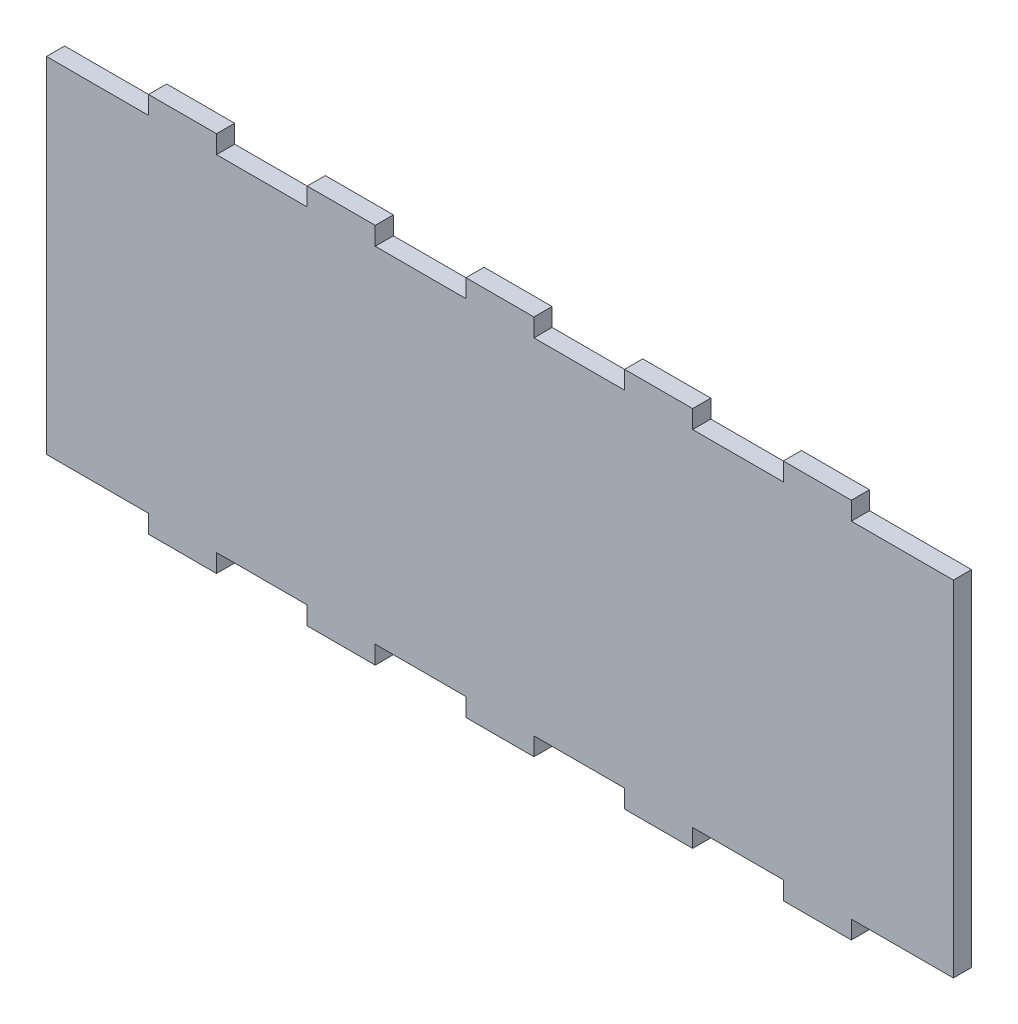
from build123d import *

# Parameters (mm, degrees)
BOSS_EXTRUDE1_DEPTH = 4


with BuildPart() as part:
    # Sketch2 → Boss-Extrude1 (new body)
    with BuildSketch(Plane.XY):
        Polygon((37.5, -76), (57.5, -76), (57.5, -80), (72.5, -80), (72.5, -76), (92.5, -76), (92.5, -80), (107.5, -80), (107.5, -76), (127.5, -76), (127.5, -80), (142.5, -80), (142.5, -76), (162.5, -76), (162.5, -80), (177.5, -80), (177.5, -76), (200, -76), (200, 0), (177.5, 0), (177.5, 4), (162.5, 4), (162.5, 0), (142.5, 0), (142.5, 4), (127.5, 4), (127.5, 0), (107.5, 0), (107.5, 4), (92.5, 4), (92.5, 0), (72.5, 0), (72.5, 4), (57.5, 4), (57.5, 0), (37.5, 0), (37.5, 4), (22.5, 4), (22.5, 0), (0, 0), (0, -76), (22.5, -76), (22.5, -80), (37.5, -80), align=None)
    extrude(amount=BOSS_EXTRUDE1_DEPTH)


solid = part.part
